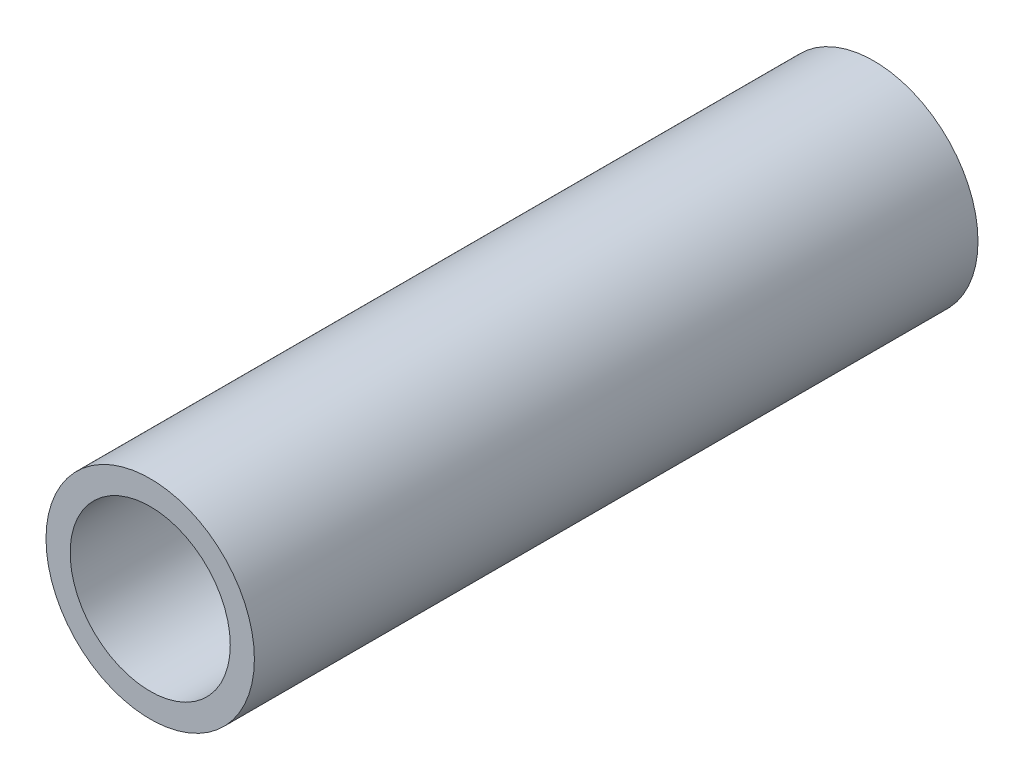
from build123d import *

# Parameters (mm, degrees)
CROQUIS1_R              = 21.6
CROQUIS1_R_2            = 16.6
SALIENTE_EXTRUIR1_DEPTH = 150


with BuildPart() as part:
    # Croquis1 → Saliente-Extruir1 (new body)
    with BuildSketch(Plane.XY):
        Circle(CROQUIS1_R)
        Circle(CROQUIS1_R_2, mode=Mode.SUBTRACT)
    extrude(amount=SALIENTE_EXTRUIR1_DEPTH)


solid = part.part
